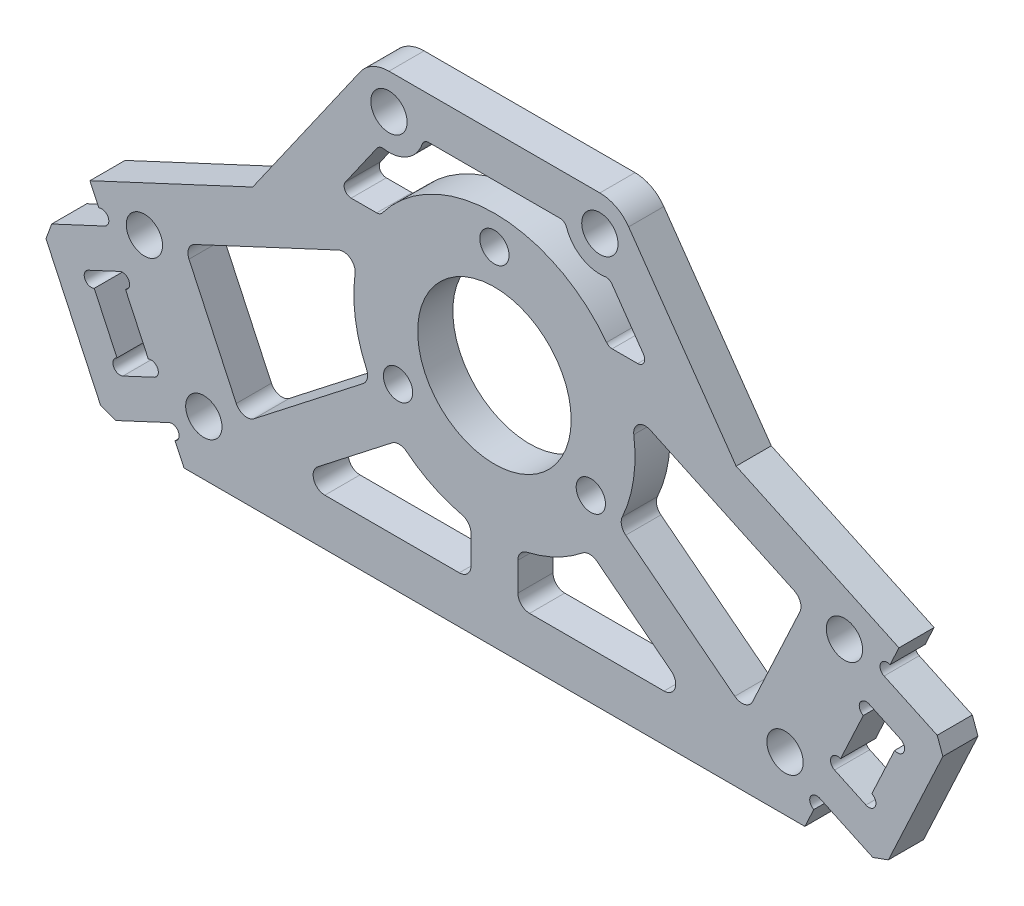
from build123d import *

# Parameters (mm, degrees)
SKETCH_1_R          = 1.25
SKETCH_1_R_2        = 6.55
EXTRUDE_1_DEPTH     = 1.5
EXTRUDE_2_DEPTH     = 3
SKETCH_3_R          = 0.6
CUT_EXTRUDE_1_DEPTH = 4
SKETCH_4_R          = 1.55
CUT_EXTRUDE_2_DEPTH = 4
CUT_EXTRUDE_3_DEPTH = 4
FILLET_1_R          = 1
CHAMFER_1_SIZE      = 1
SKETCH_6_R          = 1.55
EXTRUDE_3_DEPTH     = 3
CUT_EXTRUDE_4_DEPTH = 4
FILLET_2_R          = 0.6


with BuildPart() as part:
    # 草图1 → 凸台-拉伸1 (new body, symmetric)
    with BuildSketch(Plane.XY):
        with BuildLine():
            Line((-34.52642222, 8.609923977), (-26.496675247, -8.609923977))
            Line((-26.496675247, -8.609923977), (26.496675247, -8.609923977))
            Line((26.496675247, -8.609923977), (34.52642222, 8.609923977))
            Line((34.52642222, 8.609923977), (5.071419141, 22.345017483))
            ThreePointArc((5.071419141, 22.345017483), (0, 23.469324039), (-5.071419141, 22.345017483))
            Line((-5.071419141, 22.345017483), (-34.52642222, 8.609923977))
        make_face()
        with Locations((0, 20.969324039)):
            Circle(SKETCH_1_R, mode=Mode.SUBTRACT)
        with Locations((8.227241336, 6.719324039)):
            Circle(SKETCH_1_R, mode=Mode.SUBTRACT)
        with Locations((-8.227241336, 6.719324039)):
            Circle(SKETCH_1_R, mode=Mode.SUBTRACT)
        with Locations((0, 11.469324039)):
            Circle(SKETCH_1_R_2, mode=Mode.SUBTRACT)
    extrude(amount=EXTRUDE_1_DEPTH, both=True)

    # 草图2 → 凸台-拉伸2 (add)
    with BuildSketch(Plane.XY.offset(1.5)):
        Polygon((-33.258567434, 5.891000616), (-38.696414157, 3.355291045), (-33.202376754, -8.426710186), (-27.764530032, -5.891000616), (-29.032384817, -3.172077255), (-31.705992789, -4.418801127), (-34.664320621, 1.925353382), (-31.990712649, 3.172077255), align=None)
        Polygon((38.696414157, 3.355291045), (33.202376754, -8.426710186), (27.764530032, -5.891000616), (29.032384817, -3.172077255), (31.705992789, -4.418801127), (34.664320621, 1.925353382), (31.990712649, 3.172077255), (33.258567434, 5.891000616), align=None)
    extrude(amount=-EXTRUDE_2_DEPTH)

    # 草图3 → 切除-拉伸1 (cut, through all)
    with BuildSketch(Plane.XY.offset(1.5)):
        with Locations((-33.512138391, 6.434785288)):
            Circle(SKETCH_3_R)
        with Locations((-34.410749664, 1.38156871)):
            Circle(SKETCH_3_R)
        with Locations((-31.959563746, -3.875016455)):
            Circle(SKETCH_3_R)
        with Locations((-29.285955774, -2.628292582)):
            Circle(SKETCH_3_R)
        with Locations((-31.737141692, 2.628292582)):
            Circle(SKETCH_3_R)
        with Locations((-27.510959075, -6.434785288)):
            Circle(SKETCH_3_R)
        with Locations((27.510959075, -6.434785288)):
            Circle(SKETCH_3_R)
        with Locations((31.737141692, 2.628292582)):
            Circle(SKETCH_3_R)
        with Locations((29.285955774, -2.628292582)):
            Circle(SKETCH_3_R)
        with Locations((31.959563746, -3.875016455)):
            Circle(SKETCH_3_R)
        with Locations((34.410749664, 1.38156871)):
            Circle(SKETCH_3_R)
        with Locations((33.512138391, 6.434785288)):
            Circle(SKETCH_3_R)
    extrude(amount=-CUT_EXTRUDE_1_DEPTH, mode=Mode.SUBTRACT)

    # 草图4 → 切除-拉伸2 (cut, through all)
    with BuildSketch(Plane.XY.offset(1.5)):
        with Locations((-29.875181049, 6.917010638)):
            Circle(SKETCH_4_R)
        with Locations((-24.803761908, -3.958682806)):
            Circle(SKETCH_4_R)
        with Locations((24.803761908, -3.958682806)):
            Circle(SKETCH_4_R)
        with Locations((29.875181049, 6.917010638)):
            Circle(SKETCH_4_R)
    extrude(amount=-CUT_EXTRUDE_2_DEPTH, mode=Mode.SUBTRACT)

    # 草图5 → 切除-拉伸3 (cut, through all)
    with BuildSketch(Plane.XY.offset(1.5)):
        with BuildLine():
            Line((-11.487209375, 14.939773688), (-26.491794663, 7.943020661))
            Line((-26.491794663, 7.943020661), (-21.50545883, -2.750211042))
            Line((-21.50545883, -2.750211042), (-10.562941581, 5.775093172))
            ThreePointArc((-10.562941581, 5.775093172), (-11.939435981, 10.265219199), (-11.487209375, 14.939773688))
        make_face()
        with BuildLine():
            Line((-17.384057406, -4.609923977), (-2, -4.609923977))
            Line((-2, -4.609923977), (-2, -0.362835527))
            ThreePointArc((-2, -0.362835527), (-5.267782675, 0.687373117), (-8.104582376, 2.619705713))
            Line((-8.104582376, 2.619705713), (-17.384057406, -4.609923977))
        make_face()
        with BuildLine():
            Line((17.384057406, -4.609923977), (8.104582376, 2.619705713))
            ThreePointArc((8.104582376, 2.619705713), (5.267782675, 0.687373117), (2, -0.362835527))
            Line((2, -0.362835527), (2, -4.609923977))
            Line((2, -4.609923977), (17.384057406, -4.609923977))
        make_face()
        with BuildLine():
            Line((21.50545883, -2.750211042), (10.562941581, 5.775093172))
            ThreePointArc((10.562941581, 5.775093172), (11.939435981, 10.265219199), (11.487209375, 14.939773688))
            Line((11.487209375, 14.939773688), (26.491794663, 7.943020661))
            Line((26.491794663, 7.943020661), (21.50545883, -2.750211042))
        make_face()
    extrude(amount=-CUT_EXTRUDE_3_DEPTH, mode=Mode.SUBTRACT)

    # 圆角1
    fillet_1_edges = [part.edges().sort_by_distance(p)[0] for p in [
        (-2, -0.362835527, 0),
        (-2, -4.609923977, 0),
        (-17.384057406, -4.609923977, 0),
        (-8.104582376, 2.619705713, 0),
        (17.384057406, -4.609923977, 0),
        (2, -4.609923977, 0),
        (2, -0.362835527, 0),
        (8.104582376, 2.619705713, 0),
        (10.562941581, 5.775093172, 0),
        (11.487209375, 14.939773688, 0),
        (26.491794663, 7.943020661, 0),
        (21.50545883, -2.750211042, 0),
        (-21.50545883, -2.750211042, 0),
        (-26.491794663, 7.943020661, 0),
        (-11.487209375, 14.939773688, 0),
        (-10.562941581, 5.775093172, 0),
    ]]
    fillet(fillet_1_edges, radius=FILLET_1_R)

    # 倒角1
    chamfer_1_edges = [part.edges().sort_by_distance(p)[0] for p in [
        (-33.202376754, -8.426710186, 0),
        (-38.696414157, 3.355291045, 0),
        (38.696414157, 3.355291045, 0),
        (33.202376754, -8.426710186, 0),
    ]]
    chamfer(chamfer_1_edges, length=CHAMFER_1_SIZE)

    # 草图6 → 凸台-拉伸3 (add)
    with BuildSketch(Plane.XY.offset(1.5)):
        with BuildLine():
            Line((-11.457456133, 28.190053348), (-20.630385749, 15.089752201))
            Line((-20.630385749, 15.089752201), (-5.071419141, 22.345017483))
            ThreePointArc((-5.071419141, 22.345017483), (0, 23.469324039), (5.071419141, 22.345017483))
            Line((5.071419141, 22.345017483), (20.630385749, 15.089752201))
            Line((20.630385749, 15.089752201), (11.457456133, 28.190053348))
            ThreePointArc((11.457456133, 28.190053348), (10.38524584, 29.130356539), (9, 29.469324039))
            Line((9, 29.469324039), (-9, 29.469324039))
            ThreePointArc((-9, 29.469324039), (-10.38524584, 29.130356539), (-11.457456133, 28.190053348))
        make_face()
        with Locations((-9, 26.469324039)):
            Circle(SKETCH_6_R, mode=Mode.SUBTRACT)
        with Locations((9, 26.469324039)):
            Circle(SKETCH_6_R, mode=Mode.SUBTRACT)
    extrude(amount=-EXTRUDE_3_DEPTH)

    # 草图7 → 切除-拉伸4 (cut, through all)
    with BuildSketch(Plane.XY.offset(1.5)):
        with BuildLine():
            Line((-9.803167106, 23.578835741), (-13.379923452, 18.470698295))
            Line((-13.379923452, 18.470698295), (-9.745807228, 18.470698295))
            ThreePointArc((-9.745807228, 18.470698295), (0, 23.469324039), (9.745807228, 18.470698295))
            Line((9.745807228, 18.470698295), (13.379923452, 18.470698295))
            Line((13.379923452, 18.470698295), (9.803167106, 23.578835741))
            ThreePointArc((9.803167106, 23.578835741), (7.422496962, 23.917563046), (6.055342113, 25.895747603))
            Line((6.055342113, 25.895747603), (-6.055342113, 25.895747603))
            ThreePointArc((-6.055342113, 25.895747603), (-7.422496962, 23.917563046), (-9.803167106, 23.578835741))
        make_face()
    extrude(amount=-CUT_EXTRUDE_4_DEPTH, mode=Mode.SUBTRACT)

    # 圆角2
    fillet_2_edges = [part.edges().sort_by_distance(p)[0] for p in [
        (-9.803167106, 23.578835741, 0),
        (-6.055342113, 25.895747603, 0),
        (6.055342113, 25.895747603, 0),
        (9.803167106, 23.578835741, 0),
        (13.379923452, 18.470698295, 0),
        (9.745807228, 18.470698295, 0),
        (-9.745807228, 18.470698295, 0),
        (-13.379923452, 18.470698295, 0),
    ]]
    fillet(fillet_2_edges, radius=FILLET_2_R)


solid = part.part
